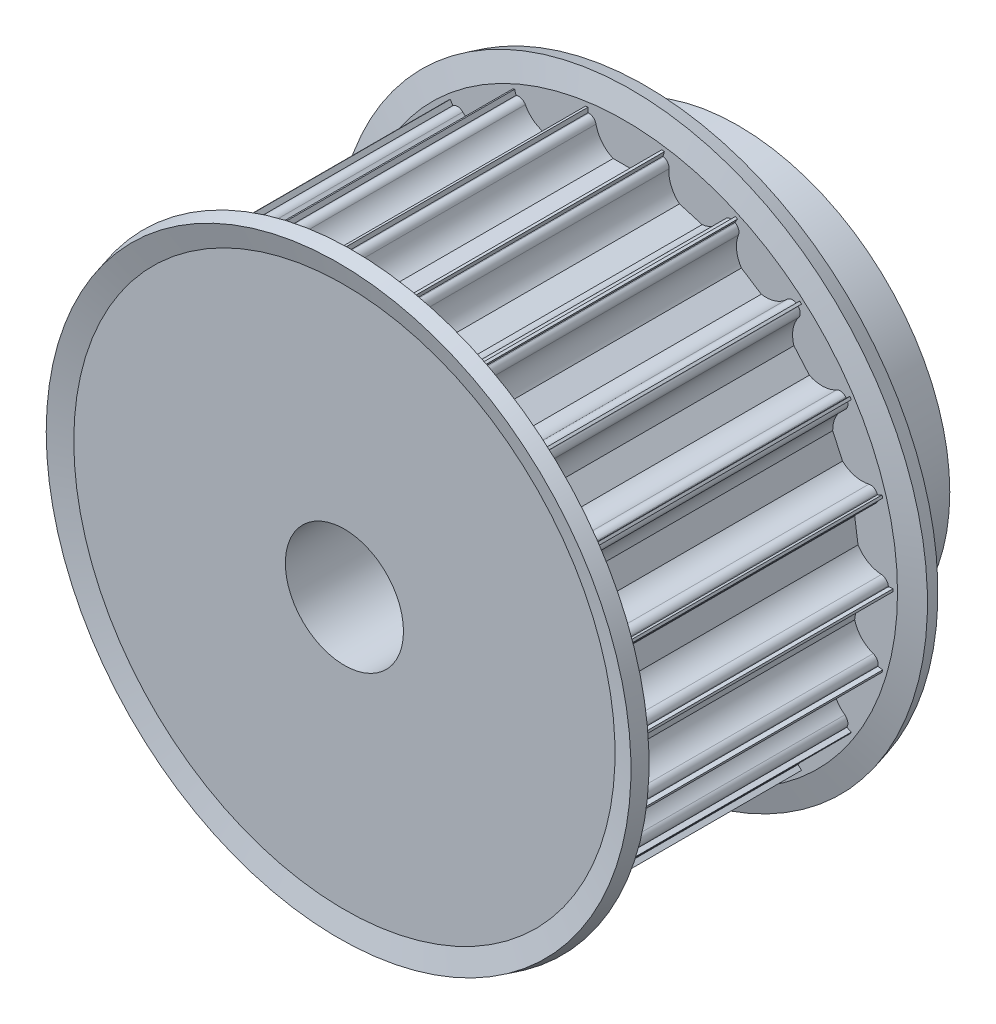
from build123d import *

# Parameters (mm, degrees)
CUT_EXTRUDE1_DEPTH = 30
CIRPATTERN1_COUNT  = 22


with BuildPart() as part:
    # Sketch1 → Revolve1 (revolve)
    with BuildSketch(Plane(origin=(0, 0, 0), x_dir=(0, 0, -1), z_dir=(1, 0, 0))):
        Polygon((0, 6), (0, 27.25), (30, 27.25), (30, 21.5), (40, 21.5), (40, 6), align=None)
    revolve(axis=Axis((0, 0, 0), (0, 0, -1)))

    # Sketch2 → Cut-Extrude1 (cut)
    with BuildSketch(Plane.XY):
        with BuildLine():
            Line((-3.674234614, 26.5), (-3.75, 26.5))
            Line((-3.75, 26.5), (-3.75, 28.5))
            Line((-3.75, 28.5), (3.75, 28.5))
            Line((3.75, 28.5), (3.75, 26.5))
            Line((3.75, 26.5), (3.674234614, 26.5))
            ThreePointArc((3.674234614, 26.5), (3.199892965, 26.330947502), (2.939387691, 25.9))
            ThreePointArc((2.939387691, 25.9), (2.331759211, 24.612435701), (1.198957881, 23.75))
            Line((1.198957881, 23.75), (-1.198957881, 23.75))
            ThreePointArc((-1.198957881, 23.75), (-2.331759211, 24.612435701), (-2.939387691, 25.9))
            ThreePointArc((-2.939387691, 25.9), (-3.199892965, 26.330947502), (-3.674234614, 26.5))
        make_face()
    cut_extrude1 = extrude(amount=-CUT_EXTRUDE1_DEPTH, mode=Mode.SUBTRACT)

    # CirPattern1: Cut-Extrude1 ×22 about axis
    cirpattern1_axis = Axis((0, 0, 0), (0, 0, 1))
    for i in range(1, CIRPATTERN1_COUNT):
        add(cut_extrude1.rotate(cirpattern1_axis, i * 360 / CIRPATTERN1_COUNT), mode=Mode.SUBTRACT)

    # Sketch3 → Revolve2 (revolve)
    with BuildSketch(Plane(origin=(0, 0, 0), x_dir=(0, 0, -1), z_dir=(1, 0, 0))):
        Polygon((30, 21.5), (30, 27.492521254), (30.591966801, 29.701771432), (29.143078062, 30.09), (28.5, 27.69), (28.5, 21.5), align=None)
        Polygon((1.5, 27.69), (1.5, 21.5), (0, 21.5), (0, 27.492521254), (-0.591966801, 29.701771432), (0.856921938, 30.09), align=None)
    revolve(axis=Axis((0, 0, 0), (0, 0, 1)))


solid = part.part
